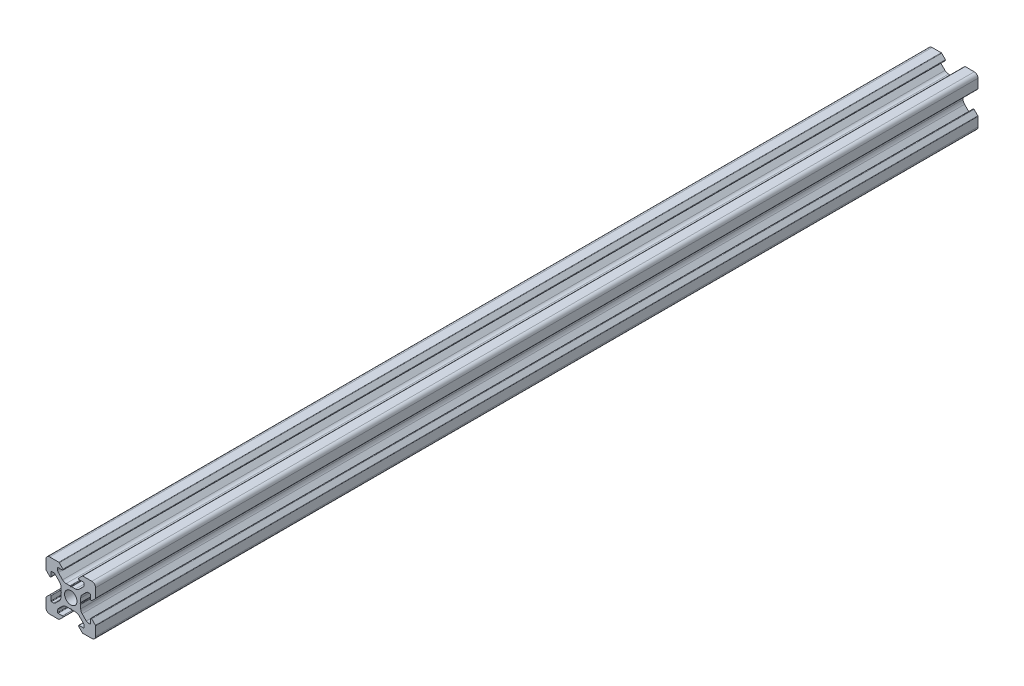
from build123d import *

# Parameters (mm, degrees)
MODEL_R             = 2.5
EXTRUDED_BODY_DEPTH = 356


with BuildPart() as part:
    # Model → Extruded body (new body)
    with BuildSketch(Plane.XY):
        with BuildLine():
            Line((-4, 0.337695265), (-4, 1.898780669))
            ThreePointArc((-4, 1.898780669), (-4.152240935, 2.664147534), (-4.585786438, 3.312994231))
            Line((-4.585786438, 3.312994231), (-6.279898987, 5.007106781))
            ThreePointArc((-6.279898987, 5.007106781), (-6.604322336, 5.223879533), (-6.987005769, 5.3))
            Line((-6.987005769, 5.3), (-7.8, 5.3))
            ThreePointArc((-7.8, 5.3), (-7.941421356, 5.241421356), (-8, 5.1))
            Line((-8, 5.1), (-8, 3.33))
            ThreePointArc((-8, 3.33), (-8.154329142, 3.099030117), (-8.426776695, 3.153223305))
            Line((-8.426776695, 3.153223305), (-9.926776695, 4.653223305))
            ThreePointArc((-9.926776695, 4.653223305), (-9.980969883, 4.734329142), (-10, 4.83))
            Line((-10, 4.83), (-10, 8.5))
            ThreePointArc((-10, 8.5), (-9.560660172, 9.560660172), (-8.5, 10))
            Line((-8.5, 10), (-4.83, 10))
            ThreePointArc((-4.83, 10), (-4.734329142, 9.980969883), (-4.653223305, 9.926776695))
            Line((-4.653223305, 9.926776695), (-3.153223305, 8.426776695))
            ThreePointArc((-3.153223305, 8.426776695), (-3.099030117, 8.154329142), (-3.33, 8))
            Line((-3.33, 8), (-5.1, 8))
            ThreePointArc((-5.1, 8), (-5.241421356, 7.941421356), (-5.3, 7.8))
            Line((-5.3, 7.8), (-5.3, 6.987005769))
            ThreePointArc((-5.3, 6.987005769), (-5.223879533, 6.604322336), (-5.007106781, 6.279898987))
            Line((-5.007106781, 6.279898987), (-3.312994231, 4.585786438))
            ThreePointArc((-3.312994231, 4.585786438), (-2.664147534, 4.152240935), (-1.898780669, 4))
            Line((-1.898780669, 4), (-0.337695265, 4))
            ThreePointArc((-0.337695265, 4), (-0.254943529, 3.98590708), (-0.181521503, 3.945217202))
            Line((-0.181521503, 3.945217202), (0, 3.8))
            Line((0, 3.8), (0.181521503, 3.945217202))
            ThreePointArc((0.181521503, 3.945217202), (0.254943529, 3.98590708), (0.337695265, 4))
            Line((0.337695265, 4), (1.898780669, 4))
            ThreePointArc((1.898780669, 4), (2.664147534, 4.152240935), (3.312994231, 4.585786438))
            Line((3.312994231, 4.585786438), (5.007106781, 6.279898987))
            ThreePointArc((5.007106781, 6.279898987), (5.223879533, 6.604322336), (5.3, 6.987005769))
            Line((5.3, 6.987005769), (5.3, 7.8))
            ThreePointArc((5.3, 7.8), (5.241421356, 7.941421356), (5.1, 8))
            Line((5.1, 8), (3.33, 8))
            ThreePointArc((3.33, 8), (3.099030117, 8.154329142), (3.153223305, 8.426776695))
            Line((3.153223305, 8.426776695), (4.653223305, 9.926776695))
            ThreePointArc((4.653223305, 9.926776695), (4.734329142, 9.980969883), (4.83, 10))
            Line((4.83, 10), (8.5, 10))
            ThreePointArc((8.5, 10), (9.560660172, 9.560660172), (10, 8.5))
            Line((10, 8.5), (10, 4.83))
            ThreePointArc((10, 4.83), (9.980969883, 4.734329142), (9.926776695, 4.653223305))
            Line((9.926776695, 4.653223305), (8.426776695, 3.153223305))
            ThreePointArc((8.426776695, 3.153223305), (8.154329142, 3.099030117), (8, 3.33))
            Line((8, 3.33), (8, 5.1))
            ThreePointArc((8, 5.1), (7.941421356, 5.241421356), (7.8, 5.3))
            Line((7.8, 5.3), (6.987005769, 5.3))
            ThreePointArc((6.987005769, 5.3), (6.604322336, 5.223879533), (6.279898987, 5.007106781))
            Line((6.279898987, 5.007106781), (4.585786438, 3.312994231))
            ThreePointArc((4.585786438, 3.312994231), (4.152240935, 2.664147534), (4, 1.898780669))
            Line((4, 1.898780669), (4, 0.337695265))
            ThreePointArc((4, 0.337695265), (3.98590708, 0.254943529), (3.945217202, 0.181521503))
            Line((3.945217202, 0.181521503), (3.8, 0))
            Line((3.8, 0), (3.945217202, -0.181521503))
            ThreePointArc((3.945217202, -0.181521503), (3.98590708, -0.254943529), (4, -0.337695265))
            Line((4, -0.337695265), (4, -1.898780669))
            ThreePointArc((4, -1.898780669), (4.152240935, -2.664147534), (4.585786438, -3.312994231))
            Line((4.585786438, -3.312994231), (6.279898987, -5.007106781))
            ThreePointArc((6.279898987, -5.007106781), (6.604322336, -5.223879533), (6.987005769, -5.3))
            Line((6.987005769, -5.3), (7.8, -5.3))
            ThreePointArc((7.8, -5.3), (7.941421356, -5.241421356), (8, -5.1))
            Line((8, -5.1), (8, -3.33))
            ThreePointArc((8, -3.33), (8.154329142, -3.099030117), (8.426776695, -3.153223305))
            Line((8.426776695, -3.153223305), (9.926776695, -4.653223305))
            ThreePointArc((9.926776695, -4.653223305), (9.980969883, -4.734329142), (10, -4.83))
            Line((10, -4.83), (10, -8.5))
            ThreePointArc((10, -8.5), (9.560660172, -9.560660172), (8.5, -10))
            Line((8.5, -10), (4.83, -10))
            ThreePointArc((4.83, -10), (4.734329142, -9.980969883), (4.653223305, -9.926776695))
            Line((4.653223305, -9.926776695), (3.153223305, -8.426776695))
            ThreePointArc((3.153223305, -8.426776695), (3.099030117, -8.154329142), (3.33, -8))
            Line((3.33, -8), (5.1, -8))
            ThreePointArc((5.1, -8), (5.241421356, -7.941421356), (5.3, -7.8))
            Line((5.3, -7.8), (5.3, -6.987005769))
            ThreePointArc((5.3, -6.987005769), (5.223879533, -6.604322336), (5.007106781, -6.279898987))
            Line((5.007106781, -6.279898987), (3.312994231, -4.585786438))
            ThreePointArc((3.312994231, -4.585786438), (2.664147534, -4.152240935), (1.898780669, -4))
            Line((1.898780669, -4), (0.337695265, -4))
            ThreePointArc((0.337695265, -4), (0.254943529, -3.98590708), (0.181521503, -3.945217202))
            Line((0.181521503, -3.945217202), (0, -3.8))
            Line((0, -3.8), (-0.181521503, -3.945217202))
            ThreePointArc((-0.181521503, -3.945217202), (-0.254943529, -3.98590708), (-0.337695265, -4))
            Line((-0.337695265, -4), (-1.898780669, -4))
            ThreePointArc((-1.898780669, -4), (-2.664147534, -4.152240935), (-3.312994231, -4.585786438))
            Line((-3.312994231, -4.585786438), (-5.007106781, -6.279898987))
            ThreePointArc((-5.007106781, -6.279898987), (-5.223879533, -6.604322336), (-5.3, -6.987005769))
            Line((-5.3, -6.987005769), (-5.3, -7.8))
            ThreePointArc((-5.3, -7.8), (-5.241421356, -7.941421356), (-5.1, -8))
            Line((-5.1, -8), (-3.33, -8))
            ThreePointArc((-3.33, -8), (-3.099030117, -8.154329142), (-3.153223305, -8.426776695))
            Line((-3.153223305, -8.426776695), (-4.653223305, -9.926776695))
            ThreePointArc((-4.653223305, -9.926776695), (-4.734329142, -9.980969883), (-4.83, -10))
            Line((-4.83, -10), (-8.5, -10))
            ThreePointArc((-8.5, -10), (-9.560660172, -9.560660172), (-10, -8.5))
            Line((-10, -8.5), (-10, -4.83))
            ThreePointArc((-10, -4.83), (-9.980969883, -4.734329142), (-9.926776695, -4.653223305))
            Line((-9.926776695, -4.653223305), (-8.426776695, -3.153223305))
            ThreePointArc((-8.426776695, -3.153223305), (-8.154329142, -3.099030117), (-8, -3.33))
            Line((-8, -3.33), (-8, -5.1))
            ThreePointArc((-8, -5.1), (-7.941421356, -5.241421356), (-7.8, -5.3))
            Line((-7.8, -5.3), (-6.987005769, -5.3))
            ThreePointArc((-6.987005769, -5.3), (-6.604322336, -5.223879533), (-6.279898987, -5.007106781))
            Line((-6.279898987, -5.007106781), (-4.585786438, -3.312994231))
            ThreePointArc((-4.585786438, -3.312994231), (-4.152240935, -2.664147534), (-4, -1.898780669))
            Line((-4, -1.898780669), (-4, -0.337695265))
            ThreePointArc((-4, -0.337695265), (-3.98590708, -0.254943529), (-3.945217202, -0.181521503))
            Line((-3.945217202, -0.181521503), (-3.8, 0))
            Line((-3.8, 0), (-3.945217202, 0.181521503))
            ThreePointArc((-3.945217202, 0.181521503), (-3.98590708, 0.254943529), (-4, 0.337695265))
        make_face()
        Circle(MODEL_R, mode=Mode.SUBTRACT)
    extrude(amount=EXTRUDED_BODY_DEPTH)


solid = part.part
